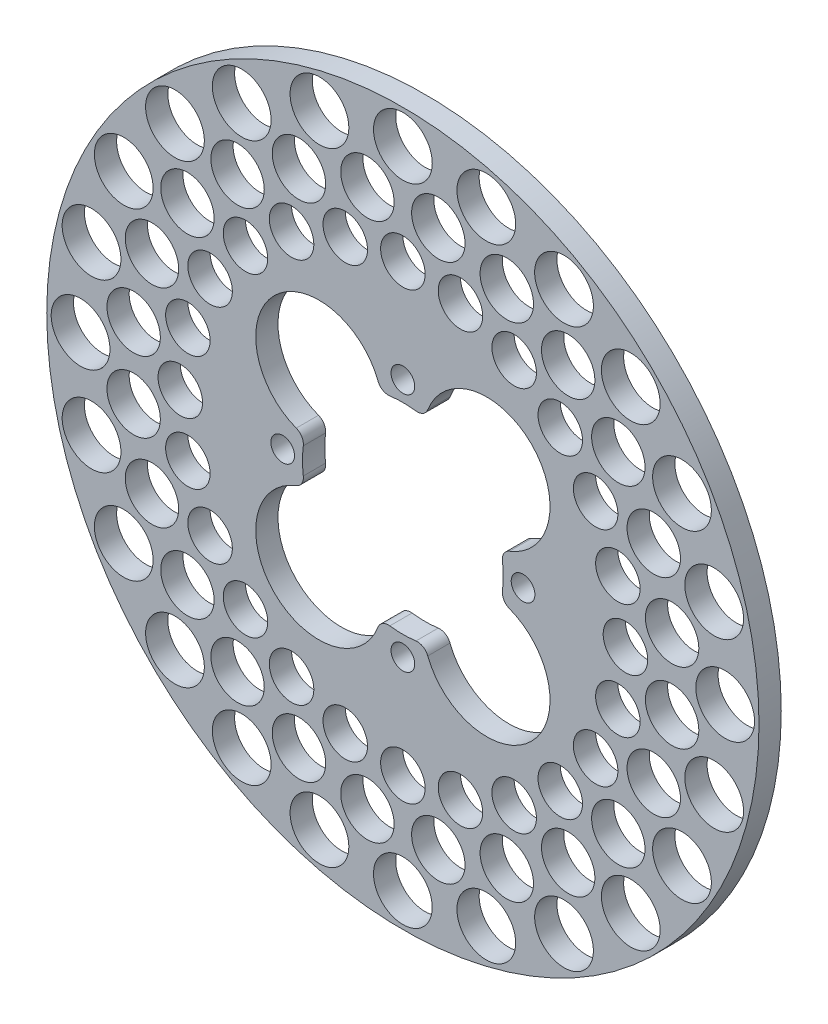
from build123d import *

# Parameters (mm, degrees)
SKETCH1_R                   = 101.6
SKETCH1_R_2                 = 6.35
SKETCH1_R_3                 = 7.62
SKETCH1_R_4                 = 8.382
BOSS_EXTRUDE1_DEPTH         = 6.35
F_1_4_CLEARANCE_HOLE1_D     = 6.7564
F_1_4_CLEARANCE_HOLE1_DEPTH = 9.652
F_1_4_CLEARANCE_HOLE1_TIP   = 2.029827343


with BuildPart() as part:
    # Sketch1 → Boss-Extrude1 (new body)
    with BuildSketch(Plane.XY):
        Circle(SKETCH1_R)
        with Locations((0, 63.5)):
            Circle(SKETCH1_R_2, mode=Mode.SUBTRACT)
        with Locations((16.435009364, 61.336289969)):
            Circle(SKETCH1_R_2, mode=Mode.SUBTRACT)
        with Locations((31.75, 54.99261314)):
            Circle(SKETCH1_R_2, mode=Mode.SUBTRACT)
        with Locations((44.901280605, 44.901280605)):
            Circle(SKETCH1_R_2, mode=Mode.SUBTRACT)
        with Locations((54.99261314, 31.75)):
            Circle(SKETCH1_R_2, mode=Mode.SUBTRACT)
        with Locations((61.336289969, 16.435009364)):
            Circle(SKETCH1_R_2, mode=Mode.SUBTRACT)
        with Locations((63.5, 0)):
            Circle(SKETCH1_R_2, mode=Mode.SUBTRACT)
        with Locations((61.336289969, -16.435009364)):
            Circle(SKETCH1_R_2, mode=Mode.SUBTRACT)
        with Locations((54.99261314, -31.75)):
            Circle(SKETCH1_R_2, mode=Mode.SUBTRACT)
        with Locations((44.901280605, -44.901280605)):
            Circle(SKETCH1_R_2, mode=Mode.SUBTRACT)
        with Locations((31.75, -54.99261314)):
            Circle(SKETCH1_R_2, mode=Mode.SUBTRACT)
        with Locations((16.435009364, -61.336289969)):
            Circle(SKETCH1_R_2, mode=Mode.SUBTRACT)
        with Locations((0, -63.5)):
            Circle(SKETCH1_R_2, mode=Mode.SUBTRACT)
        with Locations((-16.435009364, -61.336289969)):
            Circle(SKETCH1_R_2, mode=Mode.SUBTRACT)
        with Locations((-31.75, -54.99261314)):
            Circle(SKETCH1_R_2, mode=Mode.SUBTRACT)
        with Locations((-44.901280605, -44.901280605)):
            Circle(SKETCH1_R_2, mode=Mode.SUBTRACT)
        with Locations((-54.99261314, -31.75)):
            Circle(SKETCH1_R_2, mode=Mode.SUBTRACT)
        with Locations((-61.336289969, -16.435009364)):
            Circle(SKETCH1_R_2, mode=Mode.SUBTRACT)
        with Locations((-63.5, 0)):
            Circle(SKETCH1_R_2, mode=Mode.SUBTRACT)
        with Locations((-61.336289969, 16.435009364)):
            Circle(SKETCH1_R_2, mode=Mode.SUBTRACT)
        with Locations((-54.99261314, 31.75)):
            Circle(SKETCH1_R_2, mode=Mode.SUBTRACT)
        with Locations((-44.901280605, 44.901280605)):
            Circle(SKETCH1_R_2, mode=Mode.SUBTRACT)
        with Locations((-31.75, 54.99261314)):
            Circle(SKETCH1_R_2, mode=Mode.SUBTRACT)
        with Locations((-16.435009364, 61.336289969)):
            Circle(SKETCH1_R_2, mode=Mode.SUBTRACT)
        with Locations((10.111864111, 76.807233411)):
            Circle(SKETCH1_R_3, mode=Mode.SUBTRACT)
        with Locations((29.646485505, 71.572947384)):
            Circle(SKETCH1_R_3, mode=Mode.SUBTRACT)
        with Locations((47.160747905, 61.461083272)):
            Circle(SKETCH1_R_3, mode=Mode.SUBTRACT)
        with Locations((61.461083272, 47.160747905)):
            Circle(SKETCH1_R_3, mode=Mode.SUBTRACT)
        with Locations((71.572947384, 29.646485505)):
            Circle(SKETCH1_R_3, mode=Mode.SUBTRACT)
        with Locations((76.807233411, 10.111864111)):
            Circle(SKETCH1_R_3, mode=Mode.SUBTRACT)
        with Locations((76.807233411, -10.111864111)):
            Circle(SKETCH1_R_3, mode=Mode.SUBTRACT)
        with Locations((71.572947384, -29.646485505)):
            Circle(SKETCH1_R_3, mode=Mode.SUBTRACT)
        with Locations((61.461083272, -47.160747905)):
            Circle(SKETCH1_R_3, mode=Mode.SUBTRACT)
        with Locations((47.160747905, -61.461083272)):
            Circle(SKETCH1_R_3, mode=Mode.SUBTRACT)
        with Locations((29.646485505, -71.572947384)):
            Circle(SKETCH1_R_3, mode=Mode.SUBTRACT)
        with Locations((10.111864111, -76.807233411)):
            Circle(SKETCH1_R_3, mode=Mode.SUBTRACT)
        with Locations((-10.111864111, -76.807233411)):
            Circle(SKETCH1_R_3, mode=Mode.SUBTRACT)
        with Locations((-29.646485505, -71.572947384)):
            Circle(SKETCH1_R_3, mode=Mode.SUBTRACT)
        with Locations((-47.160747905, -61.461083272)):
            Circle(SKETCH1_R_3, mode=Mode.SUBTRACT)
        with Locations((-61.461083272, -47.160747905)):
            Circle(SKETCH1_R_3, mode=Mode.SUBTRACT)
        with Locations((-71.572947384, -29.646485505)):
            Circle(SKETCH1_R_3, mode=Mode.SUBTRACT)
        with Locations((-76.807233411, -10.111864111)):
            Circle(SKETCH1_R_3, mode=Mode.SUBTRACT)
        with Locations((-76.807233411, 10.111864111)):
            Circle(SKETCH1_R_3, mode=Mode.SUBTRACT)
        with Locations((-71.572947384, 29.646485505)):
            Circle(SKETCH1_R_3, mode=Mode.SUBTRACT)
        with Locations((-61.461083272, 47.160747905)):
            Circle(SKETCH1_R_3, mode=Mode.SUBTRACT)
        with Locations((-47.160747905, 61.461083272)):
            Circle(SKETCH1_R_3, mode=Mode.SUBTRACT)
        with Locations((-29.646485505, 71.572947384)):
            Circle(SKETCH1_R_3, mode=Mode.SUBTRACT)
        with Locations((-10.111864111, 76.807233411)):
            Circle(SKETCH1_R_3, mode=Mode.SUBTRACT)
        with Locations((0, 91.948)):
            Circle(SKETCH1_R_4, mode=Mode.SUBTRACT)
        with Locations((23.797893559, 88.814947876)):
            Circle(SKETCH1_R_4, mode=Mode.SUBTRACT)
        with Locations((45.974, 79.629303827)):
            Circle(SKETCH1_R_4, mode=Mode.SUBTRACT)
        with Locations((65.017054317, 65.017054317)):
            Circle(SKETCH1_R_4, mode=Mode.SUBTRACT)
        with Locations((79.629303827, 45.974)):
            Circle(SKETCH1_R_4, mode=Mode.SUBTRACT)
        with Locations((88.814947876, 23.797893559)):
            Circle(SKETCH1_R_4, mode=Mode.SUBTRACT)
        with Locations((91.948, 0)):
            Circle(SKETCH1_R_4, mode=Mode.SUBTRACT)
        with Locations((88.814947876, -23.797893559)):
            Circle(SKETCH1_R_4, mode=Mode.SUBTRACT)
        with Locations((79.629303827, -45.974)):
            Circle(SKETCH1_R_4, mode=Mode.SUBTRACT)
        with Locations((65.017054317, -65.017054317)):
            Circle(SKETCH1_R_4, mode=Mode.SUBTRACT)
        with Locations((45.974, -79.629303827)):
            Circle(SKETCH1_R_4, mode=Mode.SUBTRACT)
        with Locations((23.797893559, -88.814947876)):
            Circle(SKETCH1_R_4, mode=Mode.SUBTRACT)
        with Locations((0, -91.948)):
            Circle(SKETCH1_R_4, mode=Mode.SUBTRACT)
        with Locations((-23.797893559, -88.814947876)):
            Circle(SKETCH1_R_4, mode=Mode.SUBTRACT)
        with Locations((-45.974, -79.629303827)):
            Circle(SKETCH1_R_4, mode=Mode.SUBTRACT)
        with Locations((-65.017054317, -65.017054317)):
            Circle(SKETCH1_R_4, mode=Mode.SUBTRACT)
        with Locations((-79.629303827, -45.974)):
            Circle(SKETCH1_R_4, mode=Mode.SUBTRACT)
        with Locations((-88.814947876, -23.797893559)):
            Circle(SKETCH1_R_4, mode=Mode.SUBTRACT)
        with Locations((-91.948, 0)):
            Circle(SKETCH1_R_4, mode=Mode.SUBTRACT)
        with Locations((-88.814947876, 23.797893559)):
            Circle(SKETCH1_R_4, mode=Mode.SUBTRACT)
        with Locations((-79.629303827, 45.974)):
            Circle(SKETCH1_R_4, mode=Mode.SUBTRACT)
        with Locations((-65.017054317, 65.017054317)):
            Circle(SKETCH1_R_4, mode=Mode.SUBTRACT)
        with Locations((-45.974, 79.629303827)):
            Circle(SKETCH1_R_4, mode=Mode.SUBTRACT)
        with Locations((-23.797893559, 88.814947876)):
            Circle(SKETCH1_R_4, mode=Mode.SUBTRACT)
        with BuildLine():
            ThreePointArc((-28.409048011, -3.727209563), (-28.652505999, 0), (-28.409048011, 3.727209563))
            ThreePointArc((-28.409048011, 3.727209563), (-28.828314509, 5.763343193), (-30.417415023, 7.10363574))
            ThreePointArc((-30.417415023, 7.10363574), (-36.698388219, 36.698388219), (-7.10363574, 30.417415023))
            ThreePointArc((-7.10363574, 30.417415023), (-5.763343193, 28.828314509), (-3.727209563, 28.409048011))
            ThreePointArc((-3.727209563, 28.409048011), (0, 28.652505999), (3.727209563, 28.409048011))
            ThreePointArc((3.727209563, 28.409048011), (5.763343193, 28.828314509), (7.10363574, 30.417415023))
            ThreePointArc((7.10363574, 30.417415023), (36.698388219, 36.698388219), (30.417415023, 7.10363574))
            ThreePointArc((30.417415023, 7.10363574), (28.828314509, 5.763343193), (28.409048011, 3.727209563))
            ThreePointArc((28.409048011, 3.727209563), (28.652505999, 0), (28.409048011, -3.727209563))
            ThreePointArc((28.409048011, -3.727209563), (28.828314509, -5.763343193), (30.417415023, -7.10363574))
            ThreePointArc((30.417415023, -7.10363574), (36.698388219, -36.698388219), (7.10363574, -30.417415023))
            ThreePointArc((7.10363574, -30.417415023), (5.763343193, -28.828314509), (3.727209563, -28.409048011))
            ThreePointArc((3.727209563, -28.409048011), (0, -28.652505999), (-3.727209563, -28.409048011))
            ThreePointArc((-3.727209563, -28.409048011), (-5.763343193, -28.828314509), (-7.10363574, -30.417415023))
            ThreePointArc((-7.10363574, -30.417415023), (-36.698388219, -36.698388219), (-30.417415023, -7.10363574))
            ThreePointArc((-30.417415023, -7.10363574), (-28.828314509, -5.763343193), (-28.409048011, -3.727209563))
        make_face(mode=Mode.SUBTRACT)
    extrude(amount=BOSS_EXTRUDE1_DEPTH)

    # 1/4 Clearance Hole1
    with Locations(Plane(origin=(0, 34.29, 6.35), x_dir=(1, 0, 0), z_dir=(0, 0, 1))):
        with Locations((0, 0), (-34.29, -34.29), (34.29, -34.29), (0, -68.58)):
            Hole(F_1_4_CLEARANCE_HOLE1_D / 2, depth=F_1_4_CLEARANCE_HOLE1_DEPTH)
            with Locations((0, 0, -(F_1_4_CLEARANCE_HOLE1_DEPTH + F_1_4_CLEARANCE_HOLE1_TIP / 2))):  # 118° drill point
                Cone(0, F_1_4_CLEARANCE_HOLE1_D / 2, F_1_4_CLEARANCE_HOLE1_TIP, mode=Mode.SUBTRACT)


solid = part.part
